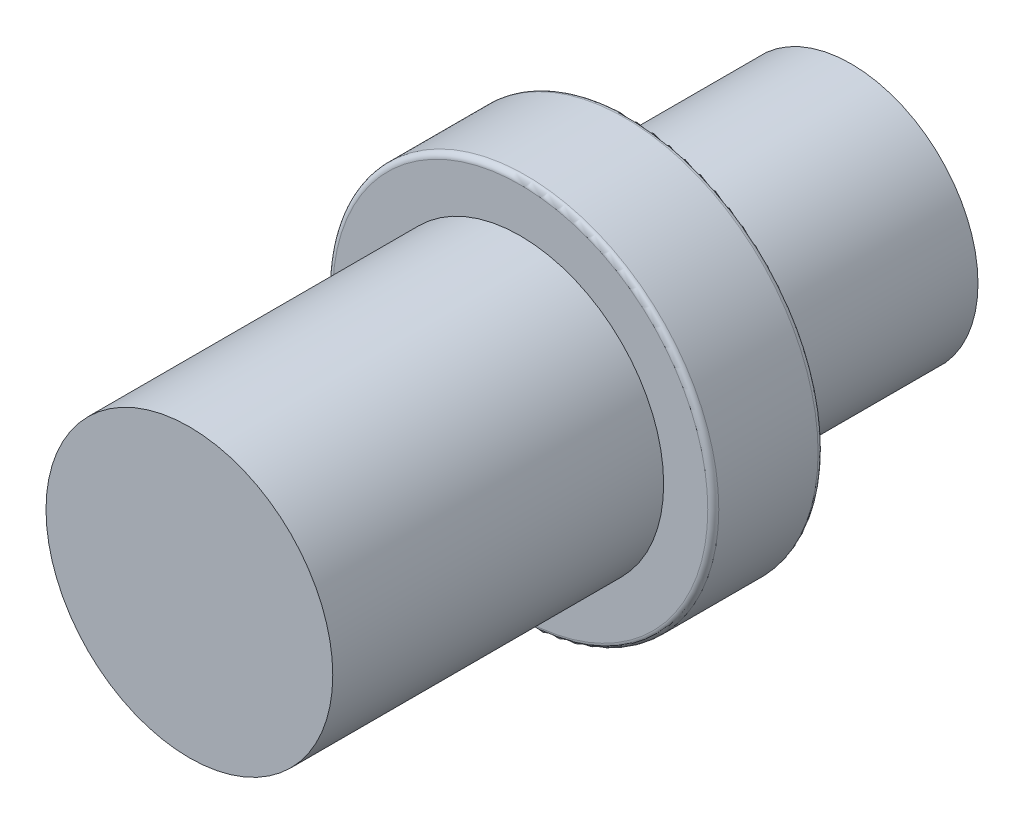
from build123d import *

# Parameters (mm, degrees)
SKETCH1_R           = 11.5
BOSS_EXTRUDE1_DEPTH = 20
SKETCH2_R           = 17.5
BOSS_EXTRUDE2_DEPTH = 10
SKETCH3_R           = 13
BOSS_EXTRUDE3_DEPTH = 30
FILLET1_R           = 0.5


with BuildPart() as part:
    # Sketch1 → Boss-Extrude1 (new body)
    with BuildSketch(Plane.XY):
        Circle(SKETCH1_R)
    extrude(amount=BOSS_EXTRUDE1_DEPTH)

    # Sketch2 → Boss-Extrude2 (add)
    with BuildSketch(Plane.XY.offset(20)):
        Circle(SKETCH2_R)
    extrude(amount=BOSS_EXTRUDE2_DEPTH)

    # Sketch3 → Boss-Extrude3 (add)
    with BuildSketch(Plane.XY.offset(30)):
        Circle(SKETCH3_R)
    extrude(amount=BOSS_EXTRUDE3_DEPTH)

    # Fillet1
    fillet1_edges = [part.edges().sort_by_distance(p)[0] for p in [
        (-17.5, 0, 20),
        (-17.5, 0, 30),
    ]]
    fillet(fillet1_edges, radius=FILLET1_R)


solid = part.part
